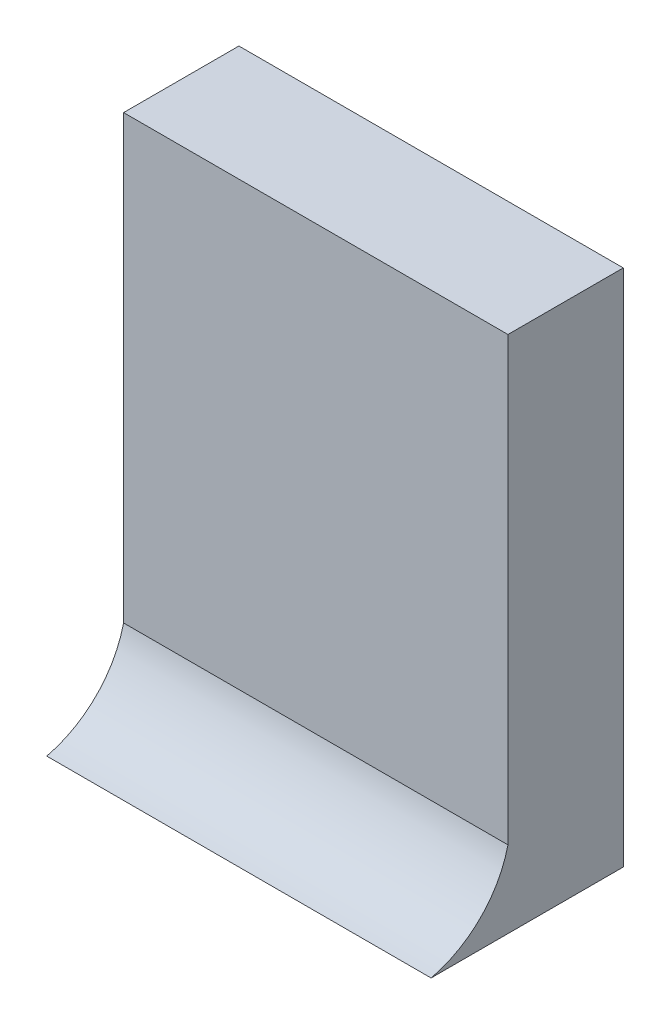
from build123d import *

# Parameters (mm, degrees)
SKETCH_1_W      = 50
SKETCH_1_H      = 67.5
EXTRUDE_1_DEPTH = 15
EXTRUDE_2_DEPTH = 50


with BuildPart() as part:
    # 草图1 → 凸台-拉伸1 (new body)
    with BuildSketch(Plane.XY):
        Rectangle(SKETCH_1_W, SKETCH_1_H)
    extrude(amount=EXTRUDE_1_DEPTH)

    # 草图5 → 凸台-拉伸2 (add)
    with BuildSketch(Plane(origin=(25, 0, 0), x_dir=(0, 0, -1), z_dir=(1, 0, 0))):
        with BuildLine():
            Line((-15, -33.75), (-25, -33.75))
            ThreePointArc((-25, -33.75), (-18.575918968, -30.174081032), (-15, -23.75))
            Line((-15, -23.75), (-15, -33.75))
        make_face()
    extrude(amount=-EXTRUDE_2_DEPTH)


solid = part.part
